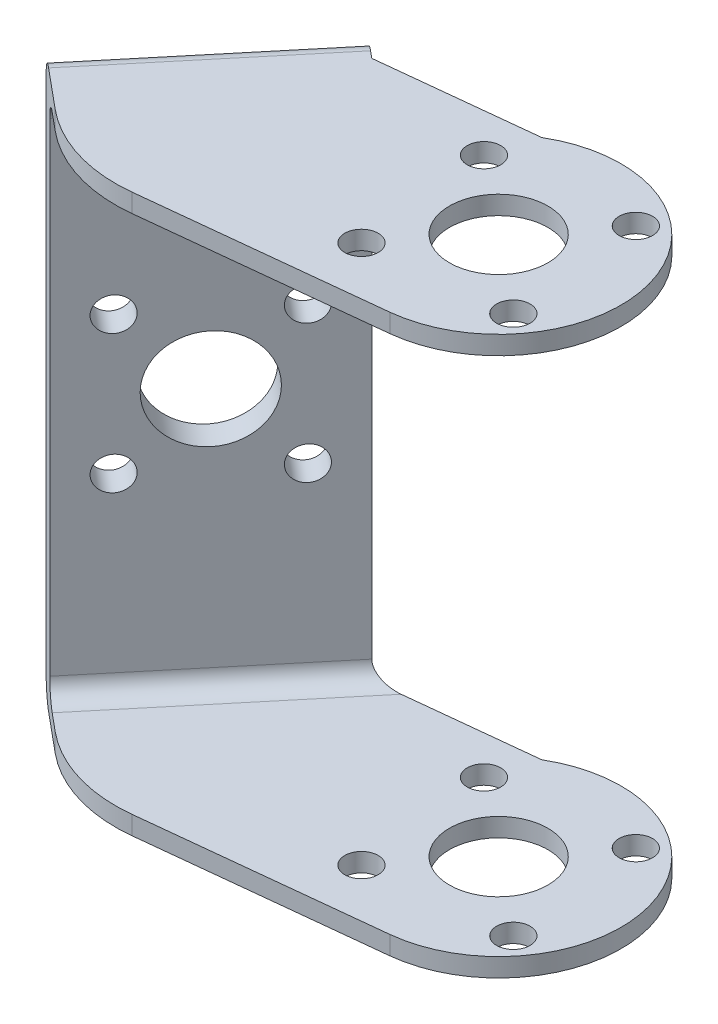
from build123d import *

# Parameters (mm, degrees)
CROQUIS1_R              = 5.3
SALIENTE_EXTRUIR1_DEPTH = 2
CROQUIS2_R              = 1.8
CORTAR_EXTRUIR1_DEPTH   = 2
CROQUIS3_W              = 24.61
CROQUIS3_H              = 60
SALIENTE_EXTRUIR2_DEPTH = 2
CROQUIS4_R              = 5.3
CROQUIS4_R_2            = 1.8
SALIENTE_EXTRUIR3_DEPTH = 2
CORTAR_EXTRUIR2_REACH   = 48.282
CROQUIS5_R              = 5.4
CROQUIS5_R_2            = 1.8
CROQUIS6_W              = 24.61
CROQUIS6_H              = 60
SALIENTE_EXTRUIR4_DEPTH = 1
CORTAR_EXTRUIR3_REACH   = 49.282
CROQUIS7_R              = 5.4
CROQUIS7_R_2            = 1.8
REDONDEO1_R             = 2


with BuildPart() as part:
    # Croquis1 → Saliente-Extruir1 (new body)
    with BuildSketch(Plane(origin=(0, 0, 0), x_dir=(1, 0, 0), z_dir=(0, 1, 0))):
        with BuildLine():
            Line((-10.994972408, -15.789813385), (14.087680331, -13.105147381))
            ThreePointArc((14.087680331, -13.105147381), (25.196689721, 4.143672323), (5.987949996, 11.351736486))
            Line((5.987949996, 11.351736486), (-10.55372573, 9.581234979))
            Line((-10.55372573, 9.581234979), (-26.287258722, -9.342507769))
            Line((-26.287258722, -9.342507769), (-22.837316291, -12.210850664))
            ThreePointArc((-22.837316291, -12.210850664), (-17.278998917, -15.200972796), (-10.994972408, -15.789813385))
        make_face()
        with Locations((12.685, 0)):
            Circle(CROQUIS1_R, mode=Mode.SUBTRACT)
    extrude(amount=SALIENTE_EXTRUIR1_DEPTH)

    # Croquis2 → Cortar-Extruir1 (cut)
    with BuildSketch(Plane(origin=(0, 2, 0), x_dir=(1, 0, 0), z_dir=(0, 1, 0))):
        with Locations((6.092709789, -8.172619517)):
            Circle(CROQUIS2_R)
        with Locations((20.857619517, -6.592290211)):
            Circle(CROQUIS2_R)
        with Locations((19.277290211, 8.172619517)):
            Circle(CROQUIS2_R)
        with Locations((4.512380483, 6.592290211)):
            Circle(CROQUIS2_R)
    extrude(amount=-CORTAR_EXTRUIR1_DEPTH, mode=Mode.SUBTRACT)

    # Croquis3 → Saliente-Extruir2 (add)
    with BuildSketch(Plane(origin=(-10.950288723, 0, -9.104262893), x_dir=(-0.639314628, 0, 0.768945256), z_dir=(-0.768945256, 0, -0.639314628))):
        with Locations((11.684706055, 30)):
            Rectangle(CROQUIS3_W, CROQUIS3_H)
    extrude(amount=SALIENTE_EXTRUIR2_DEPTH)

    # Croquis4 → Saliente-Extruir3 (add)
    with BuildSketch(Plane(origin=(0, 60, 0), x_dir=(1, 0, 0), z_dir=(0, 1, 0))):
        with BuildLine():
            Line((14.087680331, -13.105147381), (-10.994972408, -15.789813385))
            ThreePointArc((-10.994972408, -15.789813385), (-17.278998917, -15.200972796), (-22.837316291, -12.210850664))
            Line((-22.837316291, -12.210850664), (-26.287258722, -9.342507769))
            Line((-26.287258722, -9.342507769), (-10.55372573, 9.581234979))
            Line((-10.55372573, 9.581234979), (5.987949996, 11.351736486))
            ThreePointArc((5.987949996, 11.351736486), (25.196689721, 4.143672323), (14.087680331, -13.105147381))
        make_face()
        with Locations((12.685, 0)):
            Circle(CROQUIS4_R, mode=Mode.SUBTRACT)
        with Locations((4.512380483, 6.592290211)):
            Circle(CROQUIS4_R_2, mode=Mode.SUBTRACT)
        with Locations((19.277290211, 8.172619517)):
            Circle(CROQUIS4_R_2, mode=Mode.SUBTRACT)
        with Locations((20.857619517, -6.592290211)):
            Circle(CROQUIS4_R_2, mode=Mode.SUBTRACT)
        with Locations((6.092709789, -8.172619517)):
            Circle(CROQUIS4_R_2, mode=Mode.SUBTRACT)
    extrude(amount=-SALIENTE_EXTRUIR3_DEPTH)

    # Croquis5 → Cortar-Extruir2 (cut, up to next)
    with BuildSketch(Plane(origin=(-12.488179234, 0, -10.382892148), x_dir=(-0.639314628, 0, 0.768945256), z_dir=(-0.768945256, 0, -0.639314628)), mode=Mode.PRIVATE) as cortar_extruir2_sk1:
        with Locations((11.684706055, 30)):
            Circle(CROQUIS5_R)
    cortar_extruir2_tool1 = extrude(cortar_extruir2_sk1.sketch, amount=-CORTAR_EXTRUIR2_REACH, mode=Mode.PRIVATE) & part.part
    add(cortar_extruir2_tool1.solids().sort_by_distance((-19.958383, 30, -1.397993))[0], mode=Mode.SUBTRACT)
    # Croquis5 → Cortar-Extruir2 (cut, up to next)
    with BuildSketch(Plane(origin=(-12.488179234, 0, -10.382892148), x_dir=(-0.639314628, 0, 0.768945256), z_dir=(-0.768945256, 0, -0.639314628)), mode=Mode.PRIVATE) as cortar_extruir2_sk2:
        with Locations((19.109327257, 37.424621202)):
            Circle(CROQUIS5_R_2)
    cortar_extruir2_tool2 = extrude(cortar_extruir2_sk2.sketch, amount=-CORTAR_EXTRUIR2_REACH, mode=Mode.PRIVATE) & part.part
    add(cortar_extruir2_tool2.solids().sort_by_distance((-24.705052, 37.424621, 4.311134))[0], mode=Mode.SUBTRACT)
    # Croquis5 → Cortar-Extruir2 (cut, up to next)
    with BuildSketch(Plane(origin=(-12.488179234, 0, -10.382892148), x_dir=(-0.639314628, 0, 0.768945256), z_dir=(-0.768945256, 0, -0.639314628)), mode=Mode.PRIVATE) as cortar_extruir2_sk3:
        with Locations((19.109327257, 22.575378798)):
            Circle(CROQUIS5_R_2)
    cortar_extruir2_tool3 = extrude(cortar_extruir2_sk3.sketch, amount=-CORTAR_EXTRUIR2_REACH, mode=Mode.PRIVATE) & part.part
    add(cortar_extruir2_tool3.solids().sort_by_distance((-24.705052, 22.575379, 4.311134))[0], mode=Mode.SUBTRACT)
    # Croquis5 → Cortar-Extruir2 (cut, up to next)
    with BuildSketch(Plane(origin=(-12.488179234, 0, -10.382892148), x_dir=(-0.639314628, 0, 0.768945256), z_dir=(-0.768945256, 0, -0.639314628)), mode=Mode.PRIVATE) as cortar_extruir2_sk4:
        with Locations((4.260084852, 22.575378798)):
            Circle(CROQUIS5_R_2)
    cortar_extruir2_tool4 = extrude(cortar_extruir2_sk4.sketch, amount=-CORTAR_EXTRUIR2_REACH, mode=Mode.PRIVATE) & part.part
    add(cortar_extruir2_tool4.solids().sort_by_distance((-15.211714, 22.575379, -7.10712))[0], mode=Mode.SUBTRACT)
    # Croquis5 → Cortar-Extruir2 (cut, up to next)
    with BuildSketch(Plane(origin=(-12.488179234, 0, -10.382892148), x_dir=(-0.639314628, 0, 0.768945256), z_dir=(-0.768945256, 0, -0.639314628)), mode=Mode.PRIVATE) as cortar_extruir2_sk5:
        with Locations((4.260084852, 37.424621202)):
            Circle(CROQUIS5_R_2)
    cortar_extruir2_tool5 = extrude(cortar_extruir2_sk5.sketch, amount=-CORTAR_EXTRUIR2_REACH, mode=Mode.PRIVATE) & part.part
    add(cortar_extruir2_tool5.solids().sort_by_distance((-15.211714, 37.424621, -7.10712))[0], mode=Mode.SUBTRACT)

    # Croquis6 → Saliente-Extruir4 (add)
    with BuildSketch(Plane(origin=(-12.488179234, 0, -10.382892148), x_dir=(0.639314628, 0, -0.768945256), z_dir=(0.768945256, 0, 0.639314628))):
        with Locations((-11.684706055, 30)):
            Rectangle(CROQUIS6_W, CROQUIS6_H)
    extrude(amount=-SALIENTE_EXTRUIR4_DEPTH)

    # Croquis7 → Cortar-Extruir3 (cut, up to next)
    with BuildSketch(Plane(origin=(-13.25712449, 0, -11.022206776), x_dir=(-0.639314628, 0, 0.768945256), z_dir=(-0.768945256, 0, -0.639314628)), mode=Mode.PRIVATE) as cortar_extruir3_sk1:
        with Locations((11.684706055, 30)):
            Circle(CROQUIS7_R)
    cortar_extruir3_tool1 = extrude(cortar_extruir3_sk1.sketch, amount=-CORTAR_EXTRUIR3_REACH, mode=Mode.PRIVATE) & part.part
    add(cortar_extruir3_tool1.solids().sort_by_distance((-20.727328, 30, -2.037307))[0], mode=Mode.SUBTRACT)
    # Croquis7 → Cortar-Extruir3 (cut, up to next)
    with BuildSketch(Plane(origin=(-13.25712449, 0, -11.022206776), x_dir=(-0.639314628, 0, 0.768945256), z_dir=(-0.768945256, 0, -0.639314628)), mode=Mode.PRIVATE) as cortar_extruir3_sk2:
        with Locations((4.260084852, 37.424621202)):
            Circle(CROQUIS7_R_2)
    cortar_extruir3_tool2 = extrude(cortar_extruir3_sk2.sketch, amount=-CORTAR_EXTRUIR3_REACH, mode=Mode.PRIVATE) & part.part
    add(cortar_extruir3_tool2.solids().sort_by_distance((-15.980659, 37.424621, -7.746435))[0], mode=Mode.SUBTRACT)
    # Croquis7 → Cortar-Extruir3 (cut, up to next)
    with BuildSketch(Plane(origin=(-13.25712449, 0, -11.022206776), x_dir=(-0.639314628, 0, 0.768945256), z_dir=(-0.768945256, 0, -0.639314628)), mode=Mode.PRIVATE) as cortar_extruir3_sk3:
        with Locations((19.109327257, 37.424621202)):
            Circle(CROQUIS7_R_2)
    cortar_extruir3_tool3 = extrude(cortar_extruir3_sk3.sketch, amount=-CORTAR_EXTRUIR3_REACH, mode=Mode.PRIVATE) & part.part
    add(cortar_extruir3_tool3.solids().sort_by_distance((-25.473997, 37.424621, 3.67182))[0], mode=Mode.SUBTRACT)
    # Croquis7 → Cortar-Extruir3 (cut, up to next)
    with BuildSketch(Plane(origin=(-13.25712449, 0, -11.022206776), x_dir=(-0.639314628, 0, 0.768945256), z_dir=(-0.768945256, 0, -0.639314628)), mode=Mode.PRIVATE) as cortar_extruir3_sk4:
        with Locations((19.109327257, 22.575378798)):
            Circle(CROQUIS7_R_2)
    cortar_extruir3_tool4 = extrude(cortar_extruir3_sk4.sketch, amount=-CORTAR_EXTRUIR3_REACH, mode=Mode.PRIVATE) & part.part
    add(cortar_extruir3_tool4.solids().sort_by_distance((-25.473997, 22.575379, 3.67182))[0], mode=Mode.SUBTRACT)
    # Croquis7 → Cortar-Extruir3 (cut, up to next)
    with BuildSketch(Plane(origin=(-13.25712449, 0, -11.022206776), x_dir=(-0.639314628, 0, 0.768945256), z_dir=(-0.768945256, 0, -0.639314628)), mode=Mode.PRIVATE) as cortar_extruir3_sk5:
        with Locations((4.260084852, 22.575378798)):
            Circle(CROQUIS7_R_2)
    cortar_extruir3_tool5 = extrude(cortar_extruir3_sk5.sketch, amount=-CORTAR_EXTRUIR3_REACH, mode=Mode.PRIVATE) & part.part
    add(cortar_extruir3_tool5.solids().sort_by_distance((-15.980659, 22.575379, -7.746435))[0], mode=Mode.SUBTRACT)

    # Redondeo1
    redondeo1_edges = [part.edges().sort_by_distance(p)[0] for p in [
        (-20.727327994, 60, -2.037307489),
        (-18.420492226, 2, -0.119363605),
        (-18.420492226, 58, -0.119363605),
        (-20.727327994, 0, -2.037307489),
    ]]
    fillet(redondeo1_edges, radius=REDONDEO1_R)


solid = part.part
